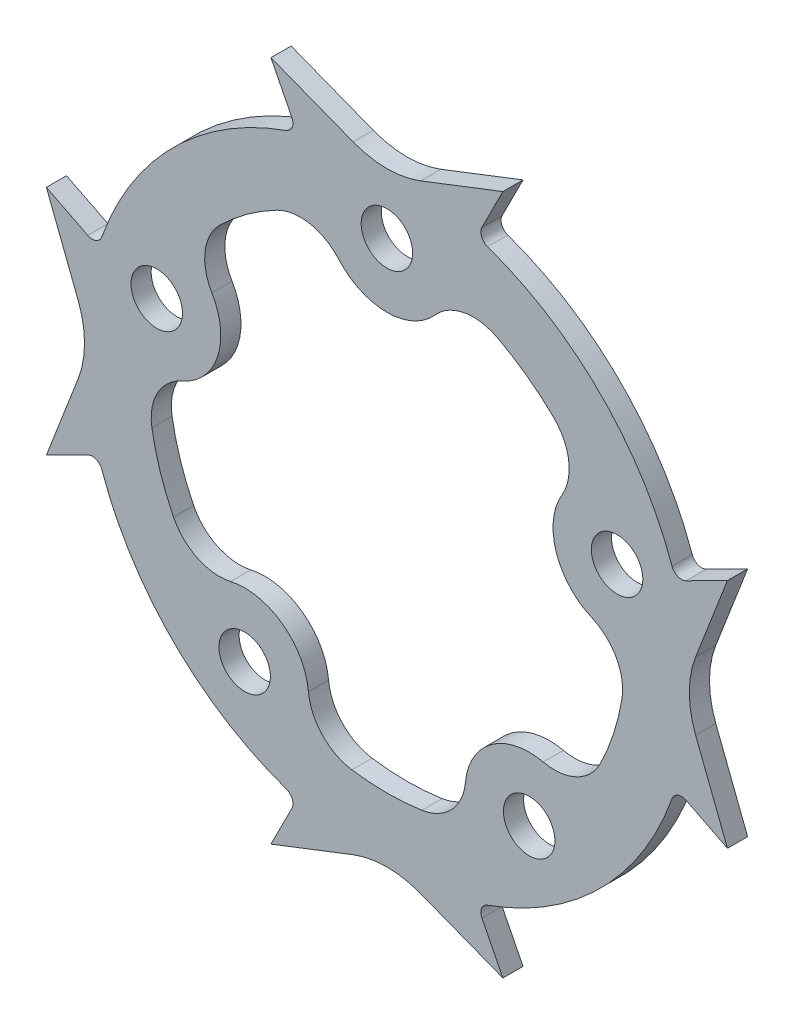
from build123d import *

# Parameters (mm, degrees)
SKETCH1_R                = 29.9847
SKETCH1_R_2              = 2.5527
BOSS_EXTRUDE1_DEPTH      = 2
BOSS_EXTRUDE2_DEPTH      = 2
FILLET1_R                = 1
CIRPATTERN1_COUNT        = 4
FILLET1_OF_CIRPATTERN1_R = 1


with BuildPart() as part:
    # Sketch1 → Boss-Extrude1 (new body)
    with BuildSketch(Plane.XY):
        Circle(SKETCH1_R)
        with Locations((-22.825356391, 7.416407865)):
            Circle(SKETCH1_R_2, mode=Mode.SUBTRACT)
        with Locations((-14.106846055, -19.416407865)):
            Circle(SKETCH1_R_2, mode=Mode.SUBTRACT)
        with Locations((14.106846055, -19.416407865)):
            Circle(SKETCH1_R_2, mode=Mode.SUBTRACT)
        with Locations((22.825356391, 7.416407865)):
            Circle(SKETCH1_R_2, mode=Mode.SUBTRACT)
        with Locations((0, 24)):
            Circle(SKETCH1_R_2, mode=Mode.SUBTRACT)
        with BuildLine():
            ThreePointArc((-10.931752655, 20.954613525), (-13.892128102, 19.120873957), (-16.550924391, 16.872046287))
            ThreePointArc((-16.550924391, 16.872046287), (-18.030688134, 13.903717203), (-17.363213066, 10.65484735))
            ThreePointArc((-17.363213066, 10.65484735), (-16.786147513, 5.454149951), (-20.309896586, 1.585887994))
            ThreePointArc((-20.309896586, 1.585887994), (-22.759533045, -0.650170928), (-23.307119088, -3.921382907))
            ThreePointArc((-23.307119088, -3.921382907), (-22.477935446, -7.303523957), (-21.160786474, -10.52711546))
            ThreePointArc((-21.160786474, -10.52711546), (-18.7950099, -12.851718542), (-15.498889917, -13.220868027))
            ThreePointArc((-15.498889917, -13.220868027), (-10.374409703, -14.279149951), (-7.78437231, -18.825793152))
            ThreePointArc((-7.78437231, -18.825793152), (-6.414733197, -21.846516076), (-3.472839121, -23.378161445))
            ThreePointArc((-3.472839121, -23.378161445), (0, -23.6347), (3.472839121, -23.378161445))
            ThreePointArc((3.472839121, -23.378161445), (6.414733197, -21.846516076), (7.78437231, -18.825793152))
            ThreePointArc((7.78437231, -18.825793152), (10.374409703, -14.279149951), (15.498889917, -13.220868027))
            ThreePointArc((15.498889917, -13.220868027), (18.7950099, -12.851718542), (21.160786474, -10.52711546))
            ThreePointArc((21.160786474, -10.52711546), (22.477935446, -7.303523957), (23.307119088, -3.921382907))
            ThreePointArc((23.307119088, -3.921382907), (22.759533045, -0.650170928), (20.309896586, 1.585887994))
            ThreePointArc((20.309896586, 1.585887994), (16.786147513, 5.454149951), (17.363213066, 10.65484735))
            ThreePointArc((17.363213066, 10.65484735), (18.030688134, 13.903717203), (16.550924391, 16.872046287))
            ThreePointArc((16.550924391, 16.872046287), (13.892128102, 19.120873957), (10.931752655, 20.954613525))
            ThreePointArc((10.931752655, 20.954613525), (7.651431793, 21.444688344), (4.767834088, 19.805925834))
            ThreePointArc((4.767834088, 19.805925834), (0, 17.65), (-4.767834088, 19.805925834))
            ThreePointArc((-4.767834088, 19.805925834), (-7.651431793, 21.444688344), (-10.931752655, 20.954613525))
        make_face(mode=Mode.SUBTRACT)
    extrude(amount=BOSS_EXTRUDE1_DEPTH)

    # Sketch1_4 → Boss-Extrude2 (add)
    with BuildSketch(Plane.XY):
        with BuildLine():
            Line((-3.355662517, 30.612532095), (-11.5, 33.770632582))
            Line((-11.5, 33.770632582), (-8.903800235, 28.632229663))
            ThreePointArc((-8.903800235, 28.632229663), (-4.502966651, 29.644654247), (0, 29.9847))
            ThreePointArc((0, 29.9847), (-1.706944937, 30.143008076), (-3.355662517, 30.612532095))
        make_face()
        with BuildLine():
            ThreePointArc((3.355662517, 30.612532095), (1.706944937, 30.143008076), (0, 29.9847))
            ThreePointArc((0, 29.9847), (4.502966651, 29.644654247), (8.903800235, 28.632229663))
            Line((8.903800235, 28.632229663), (11.5, 33.770632582))
            Line((11.5, 33.770632582), (3.355662517, 30.612532095))
        make_face()
    boss_extrude2 = extrude(amount=BOSS_EXTRUDE2_DEPTH)

    # Fillet1
    fillet1_edges = [part.edges().sort_by_distance(p)[0] for p in [
        (-8.903800235, 28.632229663, 1),
        (8.903800235, 28.632229663, 1),
    ]]
    fillet(fillet1_edges, radius=FILLET1_R)

    # CirPattern1: Boss-Extrude2 ×4 about axis
    cirpattern1_axis = Axis((0, 0, 0), (0, 0, 1))
    for i in range(1, CIRPATTERN1_COUNT):
        add(boss_extrude2.rotate(cirpattern1_axis, i * 360 / CIRPATTERN1_COUNT))

    # Fillet1 of CirPattern1
    fillet1_of_cirpattern1_edges = [part.edges().sort_by_distance(p)[0] for p in [
        (-28.632229663, -8.903800235, 1),
        (-28.632229663, 8.903800235, 1),
        (8.903800235, -28.632229663, 1),
        (-8.903800235, -28.632229663, 1),
        (28.632229663, 8.903800235, 1),
        (28.632229663, -8.903800235, 1),
    ]]
    fillet(fillet1_of_cirpattern1_edges, radius=FILLET1_OF_CIRPATTERN1_R)


solid = part.part
